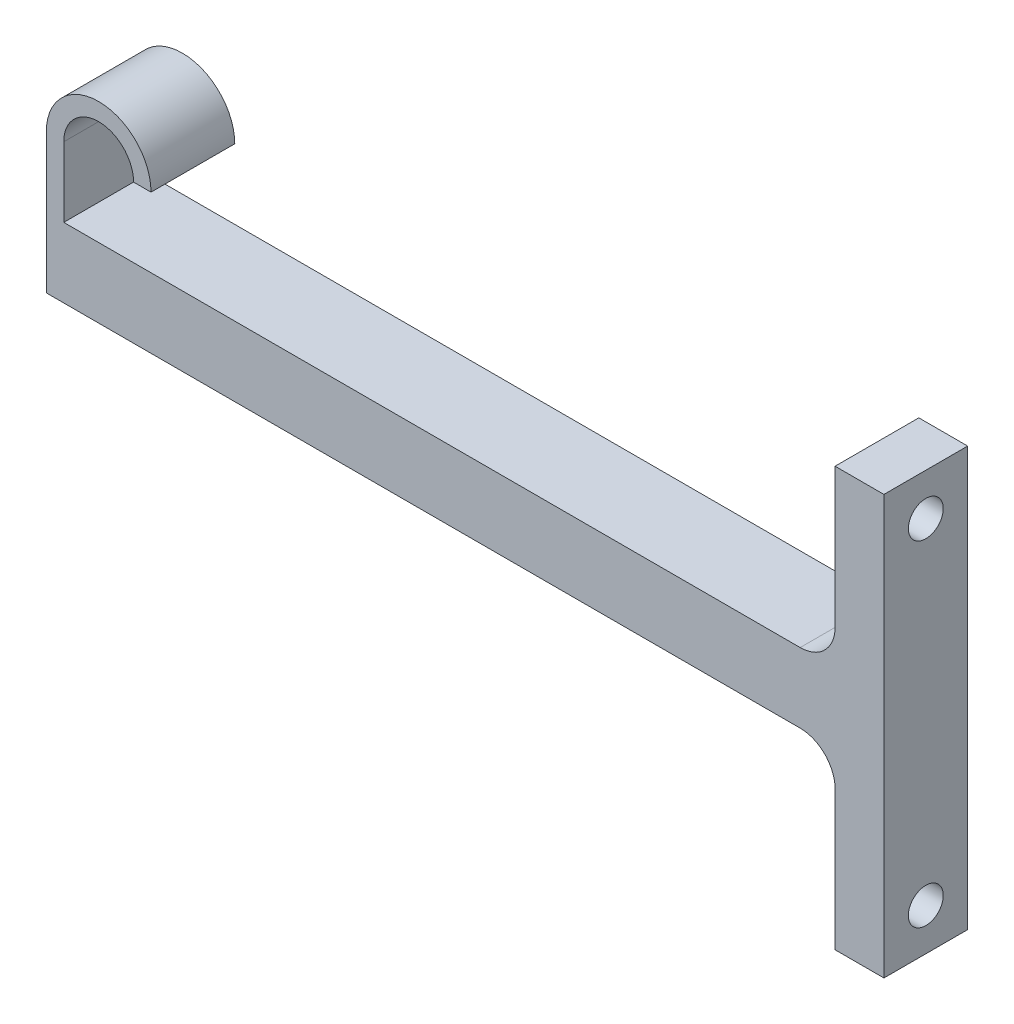
from build123d import *

# Parameters (mm, degrees)
BOSS_EXTRUDE1_DEPTH = 12
CUT_EXTRUDE2_REACH  = 122
SKETCH3_R           = 2.5
CHAMFER2_SIZE       = 2.5


with BuildPart() as part:
    # Sketch1 → Boss-Extrude1 (new body)
    with BuildSketch(Plane.XY):
        with BuildLine():
            Line((120, 35), (120, 5))
            Line((120, 5), (120, -25))
            Line((120, -25), (113, -25))
            Line((113, -25), (113, -5))
            ThreePointArc((113, -5), (111.535533906, -1.464466094), (108, 0))
            Line((108, 0), (0, 0))
            Line((0, 0), (0, 20))
            ThreePointArc((0, 20), (7.5, 27.5), (15, 20))
            Line((15, 20), (12.5, 20))
            ThreePointArc((12.5, 20), (7.5, 25), (2.5, 20))
            Line((2.5, 20), (2.5, 10))
            Line((2.5, 10), (108, 10))
            ThreePointArc((108, 10), (111.535533906, 11.464466094), (113, 15))
            Line((113, 15), (113, 35))
            Line((113, 35), (120, 35))
        make_face()
    extrude(amount=BOSS_EXTRUDE1_DEPTH)

    # Sketch3 → Cut-Extrude2 (cut, up to next)
    with BuildSketch(Plane(origin=(120, 0, 0), x_dir=(0, 0, -1), z_dir=(1, 0, 0)), mode=Mode.PRIVATE) as cut_extrude2_sk1:
        with Locations((-6, 29)):
            Circle(SKETCH3_R)
    cut_extrude2_tool1 = extrude(cut_extrude2_sk1.sketch, amount=-CUT_EXTRUDE2_REACH, mode=Mode.PRIVATE) & part.part
    add(cut_extrude2_tool1.solids().sort_by_distance((120, 29, 6))[0], mode=Mode.SUBTRACT)
    # Sketch3 → Cut-Extrude2 (cut, up to next)
    with BuildSketch(Plane(origin=(120, 0, 0), x_dir=(0, 0, -1), z_dir=(1, 0, 0)), mode=Mode.PRIVATE) as cut_extrude2_sk2:
        with Locations((-6, -19)):
            Circle(SKETCH3_R)
    cut_extrude2_tool2 = extrude(cut_extrude2_sk2.sketch, amount=-CUT_EXTRUDE2_REACH, mode=Mode.PRIVATE) & part.part
    add(cut_extrude2_tool2.solids().sort_by_distance((120, -19, 6))[0], mode=Mode.SUBTRACT)

    # Chamfer2
    chamfer2_edges = [part.edges().sort_by_distance(p)[0] for p in [
        (113, 29, 8.5),
        (113, -19, 8.5),
    ]]
    chamfer(chamfer2_edges, length=CHAMFER2_SIZE)


solid = part.part
